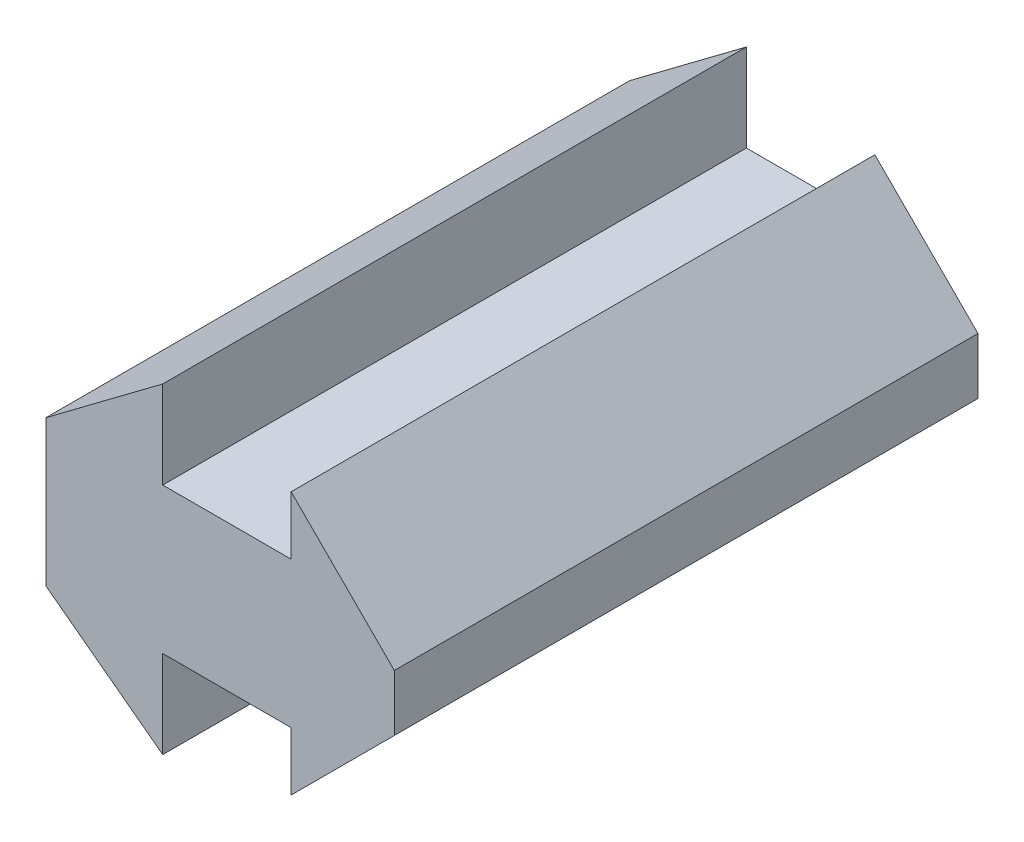
from build123d import *

# Parameters (mm, degrees)
BOSS_EXTRU_1_DEPTH = 20


with BuildPart() as part:
    # ProfileRainureEsquisse → Boss.-Extru.1 (new body)
    with BuildSketch(Plane.XY):
        Polygon((0, 0), (0, 5), (4, 8), (4, 5), (8.4, 5), (8.4, 7), (11.935533906, 3.464466094), (11.935533906, 1.535533906), (8.4, -2), (8.4, 0), (4, 0), (4, -3), align=None)
    extrude(amount=BOSS_EXTRU_1_DEPTH)


solid = part.part
